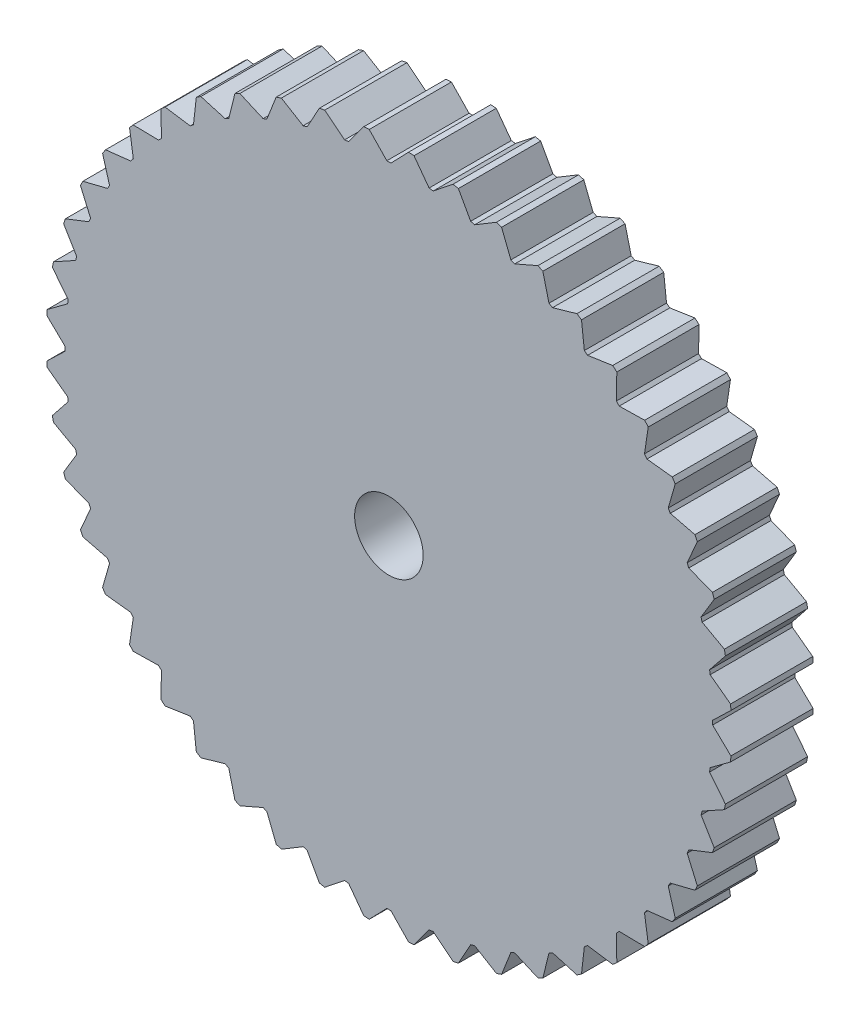
from build123d import *

# Parameters (mm, degrees)
SKETCH1_R           = 50
SKETCH1_R_2         = 5
BOSS_EXTRUDE1_DEPTH = 12
CUT_EXTRUDE1_DEPTH  = 12


with BuildPart() as part:
    # Sketch1 → Boss-Extrude1 (new body)
    with BuildSketch(Plane.XY):
        Circle(SKETCH1_R)
        Circle(SKETCH1_R_2, mode=Mode.SUBTRACT)
    extrude(amount=BOSS_EXTRUDE1_DEPTH)

    # Sketch2 → Cut-Extrude1 (cut)
    with BuildSketch(Plane.XY.offset(12)):
        Polygon((-3, 50.05), (-0.3, 47.25), (0.3, 47.25), (3, 50.05), align=None)
        Polygon((6.464796041, 46.806611842), (9.507170505, 49.230236735), (3.558501336, 50.013393888), (5.869929124, 46.884927558), align=None)
        Polygon((12.518977629, 45.562349579), (15.851670686, 47.56813047), (10.056115729, 49.121044741), (11.939422133, 45.717641006), align=None)
        Polygon((18.358956039, 43.538502881), (21.924944387, 45.092120305), (16.381667192, 47.388220899), (17.804628319, 43.768112941), align=None)
        Polygon((23.884807621, 40.769700329), (27.623076211, 41.844571459), (22.426923789, 44.844571459), (23.365192379, 41.069700329), align=None)
        Polygon((29.001983523, 37.3033169), (32.848569543, 37.881050395), (28.088449501, 41.533618969), (28.525971519, 37.668573757), align=None)
        Polygon((33.622927445, 33.198663377), (37.512014742, 33.269374055), (33.269374055, 37.512014742), (33.198663377, 33.622927445), align=None)
        Polygon((37.668573757, 28.525971519), (41.533618969, 28.088449501), (37.881050395, 32.848569543), (37.3033169, 29.001983523), align=None)
        Polygon((41.069700329, 23.365192379), (44.844571459, 22.426923789), (41.844571459, 27.623076211), (40.769700329, 23.884807621), align=None)
        Polygon((43.768112941, 17.804628319), (47.388220899, 16.381667192), (45.092120305, 21.924944387), (43.538502881, 18.358956039), align=None)
        Polygon((45.717641006, 11.939422133), (49.121044741, 10.056115729), (47.56813047, 15.851670686), (45.562349579, 12.518977629), align=None)
        Polygon((46.884927558, 5.869929124), (50.013393888, 3.558501336), (49.230236735, 9.507170505), (46.806611842, 6.464796041), align=None)
        Polygon((47.25, -0.3), (50.05, -3), (50.05, 3), (47.25, 0.3), align=None)
        Polygon((46.806611842, -6.464796041), (49.230236735, -9.507170505), (50.013393888, -3.558501336), (46.884927558, -5.869929124), align=None)
        Polygon((45.562349579, -12.518977629), (47.56813047, -15.851670686), (49.121044741, -10.056115729), (45.717641006, -11.939422133), align=None)
        Polygon((43.538502881, -18.358956039), (45.092120305, -21.924944387), (47.388220899, -16.381667192), (43.768112941, -17.804628319), align=None)
        Polygon((40.769700329, -23.884807621), (41.844571459, -27.623076211), (44.844571459, -22.426923789), (41.069700329, -23.365192379), align=None)
        Polygon((37.3033169, -29.001983523), (37.881050395, -32.848569543), (41.533618969, -28.088449501), (37.668573757, -28.525971519), align=None)
        Polygon((33.198663377, -33.622927445), (33.269374055, -37.512014742), (37.512014742, -33.269374055), (33.622927445, -33.198663377), align=None)
        Polygon((28.525971519, -37.668573757), (28.088449501, -41.533618969), (32.848569543, -37.881050395), (29.001983523, -37.3033169), align=None)
        Polygon((23.365192379, -41.069700329), (22.426923789, -44.844571459), (27.623076211, -41.844571459), (23.884807621, -40.769700329), align=None)
        Polygon((17.804628319, -43.768112941), (16.381667192, -47.388220899), (21.924944387, -45.092120305), (18.358956039, -43.538502881), align=None)
        Polygon((11.939422133, -45.717641006), (10.056115729, -49.121044741), (15.851670686, -47.56813047), (12.518977629, -45.562349579), align=None)
        Polygon((5.869929124, -46.884927558), (3.558501336, -50.013393888), (9.507170505, -49.230236735), (6.464796041, -46.806611842), align=None)
        Polygon((-0.3, -47.25), (-3, -50.05), (3, -50.05), (0.3, -47.25), align=None)
        Polygon((-6.464796041, -46.806611842), (-9.507170505, -49.230236735), (-3.558501336, -50.013393888), (-5.869929124, -46.884927558), align=None)
        Polygon((-12.518977629, -45.562349579), (-15.851670686, -47.56813047), (-10.056115729, -49.121044741), (-11.939422133, -45.717641006), align=None)
        Polygon((-18.358956039, -43.538502881), (-21.924944387, -45.092120305), (-16.381667192, -47.388220899), (-17.804628319, -43.768112941), align=None)
        Polygon((-23.884807621, -40.769700329), (-27.623076211, -41.844571459), (-22.426923789, -44.844571459), (-23.365192379, -41.069700329), align=None)
        Polygon((-29.001983523, -37.3033169), (-32.848569543, -37.881050395), (-28.088449501, -41.533618969), (-28.525971519, -37.668573757), align=None)
        Polygon((-33.622927445, -33.198663377), (-37.512014742, -33.269374055), (-33.269374055, -37.512014742), (-33.198663377, -33.622927445), align=None)
        Polygon((-37.668573757, -28.525971519), (-41.533618969, -28.088449501), (-37.881050395, -32.848569543), (-37.3033169, -29.001983523), align=None)
        Polygon((-41.069700329, -23.365192379), (-44.844571459, -22.426923789), (-41.844571459, -27.623076211), (-40.769700329, -23.884807621), align=None)
        Polygon((-43.768112941, -17.804628319), (-47.388220899, -16.381667192), (-45.092120305, -21.924944387), (-43.538502881, -18.358956039), align=None)
        Polygon((-45.717641006, -11.939422133), (-49.121044741, -10.056115729), (-47.56813047, -15.851670686), (-45.562349579, -12.518977629), align=None)
        Polygon((-46.884927558, -5.869929124), (-50.013393888, -3.558501336), (-49.230236735, -9.507170505), (-46.806611842, -6.464796041), align=None)
        Polygon((-47.25, 0.3), (-50.05, 3), (-50.05, -3), (-47.25, -0.3), align=None)
        Polygon((-46.806611842, 6.464796041), (-49.230236735, 9.507170505), (-50.013393888, 3.558501336), (-46.884927558, 5.869929124), align=None)
        Polygon((-45.562349579, 12.518977629), (-47.56813047, 15.851670686), (-49.121044741, 10.056115729), (-45.717641006, 11.939422133), align=None)
        Polygon((-43.538502881, 18.358956039), (-45.092120305, 21.924944387), (-47.388220899, 16.381667192), (-43.768112941, 17.804628319), align=None)
        Polygon((-40.769700329, 23.884807621), (-41.844571459, 27.623076211), (-44.844571459, 22.426923789), (-41.069700329, 23.365192379), align=None)
        Polygon((-37.3033169, 29.001983523), (-37.881050395, 32.848569543), (-41.533618969, 28.088449501), (-37.668573757, 28.525971519), align=None)
        Polygon((-33.198663377, 33.622927445), (-33.269374055, 37.512014742), (-37.512014742, 33.269374055), (-33.622927445, 33.198663377), align=None)
        Polygon((-28.525971519, 37.668573757), (-28.088449501, 41.533618969), (-32.848569543, 37.881050395), (-29.001983523, 37.3033169), align=None)
        Polygon((-23.365192379, 41.069700329), (-22.426923789, 44.844571459), (-27.623076211, 41.844571459), (-23.884807621, 40.769700329), align=None)
        Polygon((-17.804628319, 43.768112941), (-16.381667192, 47.388220899), (-21.924944387, 45.092120305), (-18.358956039, 43.538502881), align=None)
        Polygon((-11.939422133, 45.717641006), (-10.056115729, 49.121044741), (-15.851670686, 47.56813047), (-12.518977629, 45.562349579), align=None)
        Polygon((-5.869929124, 46.884927558), (-3.558501336, 50.013393888), (-9.507170505, 49.230236735), (-6.464796041, 46.806611842), align=None)
    extrude(amount=-CUT_EXTRUDE1_DEPTH, mode=Mode.SUBTRACT)


solid = part.part
